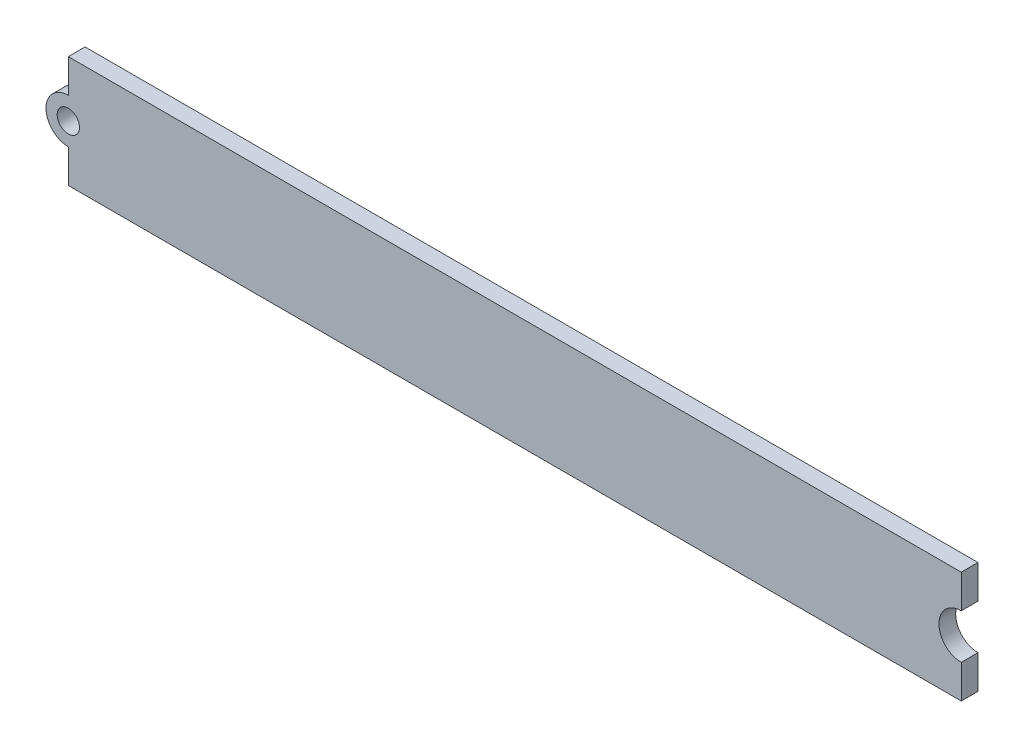
from build123d import *

# Parameters (mm, degrees)
ESQUISSE1_R        = 1
BOSS_EXTRU_1_DEPTH = 1.5


with BuildPart() as part:
    # Esquisse1 → Boss.-Extru.1 (new body)
    with BuildSketch(Plane.XY):
        with BuildLine():
            Line((-40, -2), (-40, -5))
            Line((-40, -5), (40, -5))
            Line((40, -5), (40, -2))
            ThreePointArc((40, -2), (38, 0), (40, 2))
            Line((40, 2), (40, 5))
            Line((40, 5), (-40, 5))
            Line((-40, 5), (-40, 2))
            ThreePointArc((-40, 2), (-42, 0), (-40, -2))
        make_face()
        with Locations((-40, 0)):
            Circle(ESQUISSE1_R, mode=Mode.SUBTRACT)
    extrude(amount=BOSS_EXTRU_1_DEPTH)


solid = part.part
